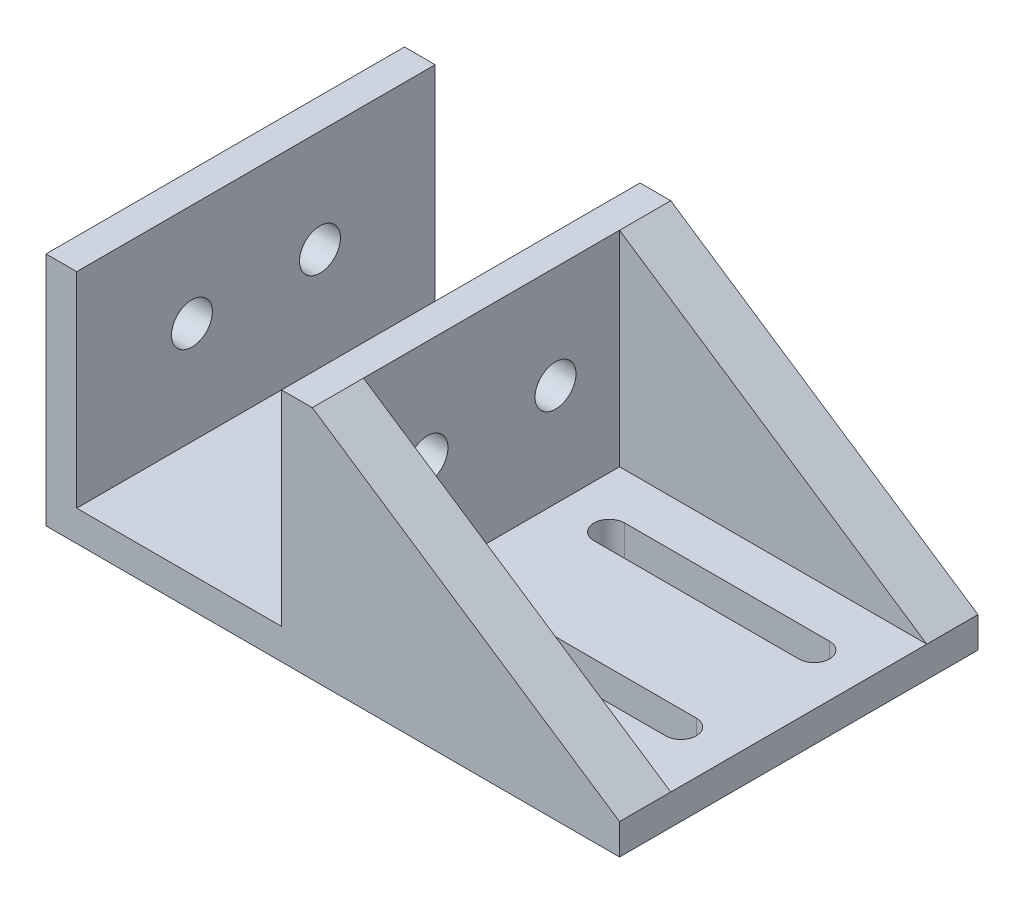
from build123d import *

# Parameters (mm, degrees)
BOSS_EXTRUDE1_DEPTH     = 35
CUT_EXTRUDE2_DEPTH      = 21
CUT_EXTRUDE2_DEPTH_BACK = 4
BOSS_EXTRUDE2_DEPTH     = 35
SKETCH5_W               = 30
SKETCH5_H               = 25
CUT_EXTRUDE3_DEPTH      = 20
SKETCH6_R               = 2
CUT_EXTRUDE4_DEPTH      = 27


with BuildPart() as part:
    # Sketch1 → Boss-Extrude1 (new body)
    with BuildSketch(Plane.XY):
        Polygon((0, 23), (0, 0), (56, 0), (56, 3), (26, 3), (26, 23), (23, 23), (23, 3), (3, 3), (3, 23), align=None)
    extrude(amount=BOSS_EXTRUDE1_DEPTH)

    # Sketch3 → Cut-Extrude2 (cut, two sides)
    with BuildSketch(Plane(origin=(0, 3, 0), x_dir=(1, 0, 0), z_dir=(0, 1, 0))) as cut_extrude2_sk:
        with BuildLine():
            Line((31, -9.5), (51, -9.5))
            ThreePointArc((51, -9.5), (52.5, -11), (51, -12.5))
            Line((51, -12.5), (31, -12.5))
            ThreePointArc((31, -12.5), (29.5, -11), (31, -9.5))
        make_face()
        with BuildLine():
            Line((31, -25.5), (51, -25.5))
            ThreePointArc((51, -25.5), (52.5, -24), (51, -22.5))
            Line((51, -22.5), (31, -22.5))
            ThreePointArc((31, -22.5), (29.5, -24), (31, -25.5))
        make_face()
    extrude(amount=CUT_EXTRUDE2_DEPTH, mode=Mode.SUBTRACT)
    extrude(cut_extrude2_sk.sketch, amount=-CUT_EXTRUDE2_DEPTH_BACK, mode=Mode.SUBTRACT)

    # Sketch4 → Boss-Extrude2 (add, through all)
    with BuildSketch(Plane.XY.offset(35)):
        Polygon((26, 23), (26, 3), (56, 3), align=None)
    extrude(amount=-BOSS_EXTRUDE2_DEPTH)

    # Sketch5 → Cut-Extrude3 (cut)
    with BuildSketch(Plane(origin=(0, 23, 0), x_dir=(1, 0, 0), z_dir=(0, 1, 0))):
        with Locations((41, -17.5)):
            Rectangle(SKETCH5_W, SKETCH5_H)
    extrude(amount=-CUT_EXTRUDE3_DEPTH, mode=Mode.SUBTRACT)

    # Sketch6 → Cut-Extrude4 (cut, through all)
    with BuildSketch(Plane(origin=(26, 0, 0), x_dir=(0, 0, -1), z_dir=(1, 0, 0))):
        with Locations((-23.75, 13)):
            Circle(SKETCH6_R)
        with Locations((-11.25, 13)):
            Circle(SKETCH6_R)
    extrude(amount=-CUT_EXTRUDE4_DEPTH, mode=Mode.SUBTRACT)


solid = part.part
